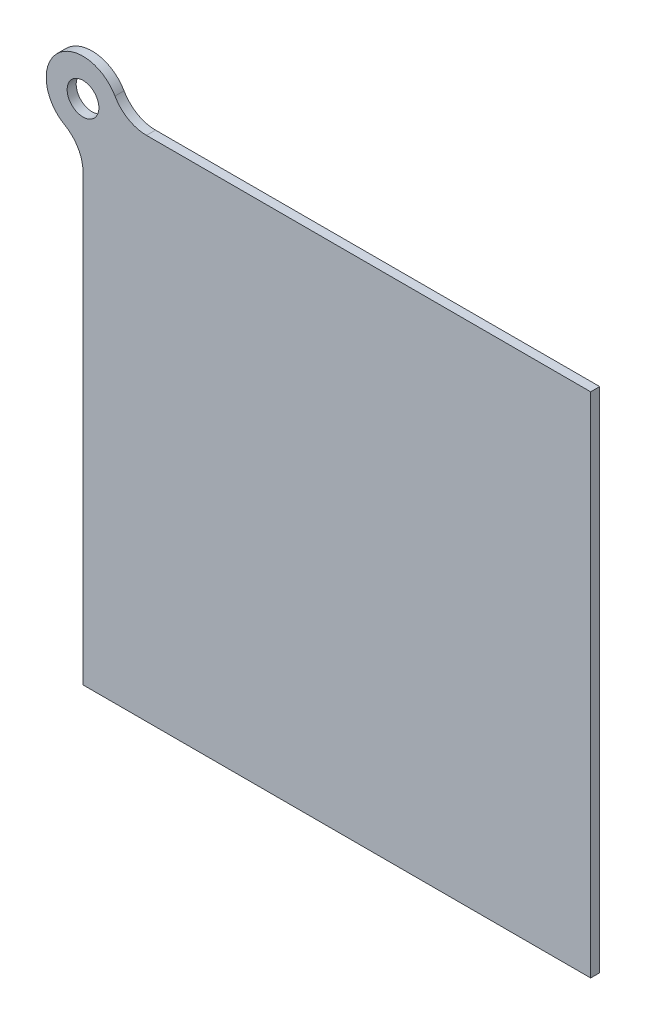
from build123d import *

# Parameters (mm, degrees)
SKETCH1_R           = 4.445
BOSS_EXTRUDE1_DEPTH = 2.54
FILLET1_R           = 10.16


with BuildPart() as part:
    # Sketch1 → Boss-Extrude1 (new body)
    with BuildSketch(Plane.XY):
        with BuildLine():
            Line((0, -10.3124), (0, -142.24))
            Line((0, -142.24), (142.24, -142.24))
            Line((142.24, -142.24), (142.24, 0))
            Line((142.24, 0), (10.3124, 0))
            ThreePointArc((10.3124, 0), (-7.29196797, 7.29196797), (0, -10.3124))
        make_face()
        Circle(SKETCH1_R, mode=Mode.SUBTRACT)
    extrude(amount=BOSS_EXTRUDE1_DEPTH)

    # Fillet1
    fillet1_edges = [part.edges().sort_by_distance(p)[0] for p in [
        (0, -10.3124, 1.27),
        (10.3124, 0, 1.27),
    ]]
    fillet(fillet1_edges, radius=FILLET1_R)


solid = part.part
